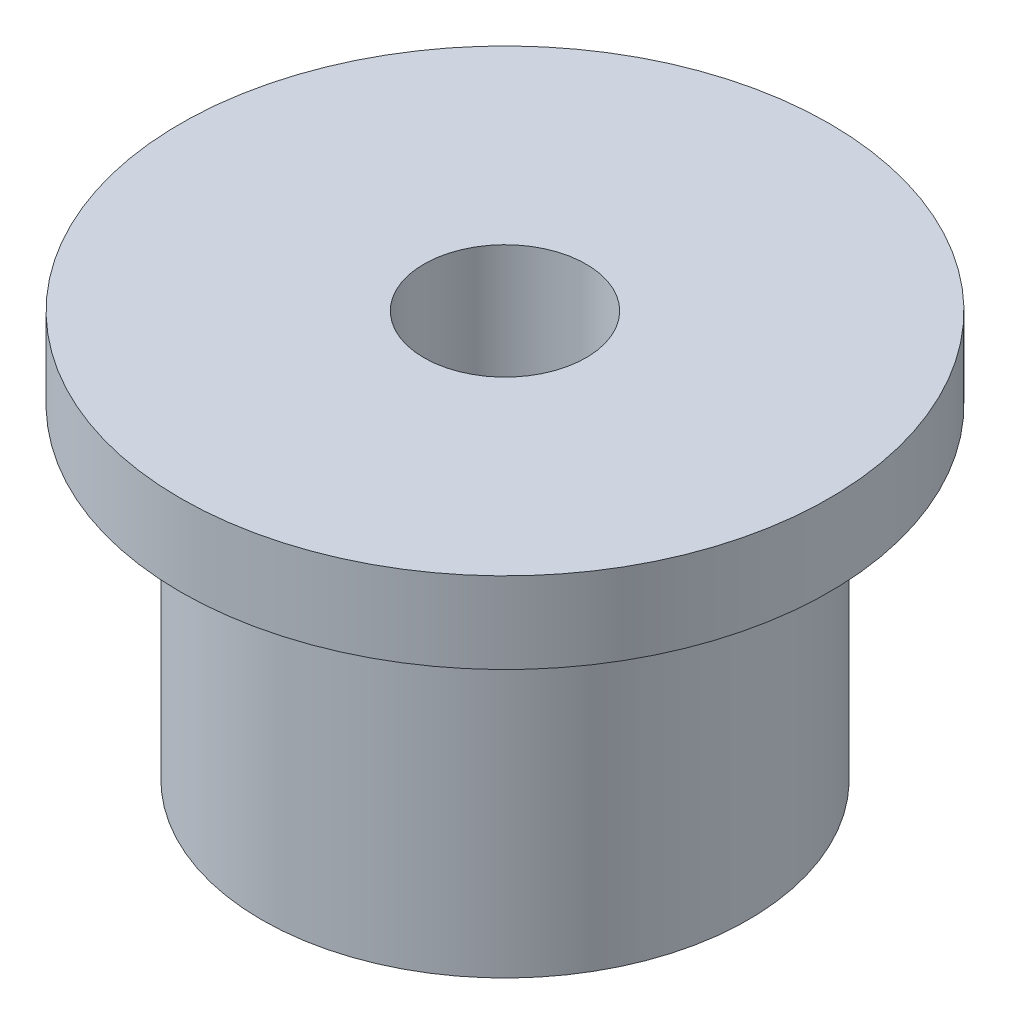
from build123d import *


with BuildPart() as part:
    # Sketch1 → Revolve1 (revolve)
    with BuildSketch(Plane.XY):
        Polygon((25, 62.5), (100, 62.5), (100, 37.5), (75, 37.5), (75, -62.5), (25, -62.5), align=None)
    revolve(axis=Axis((0, 62.5, 0), (0, -1, 0)))


solid = part.part
